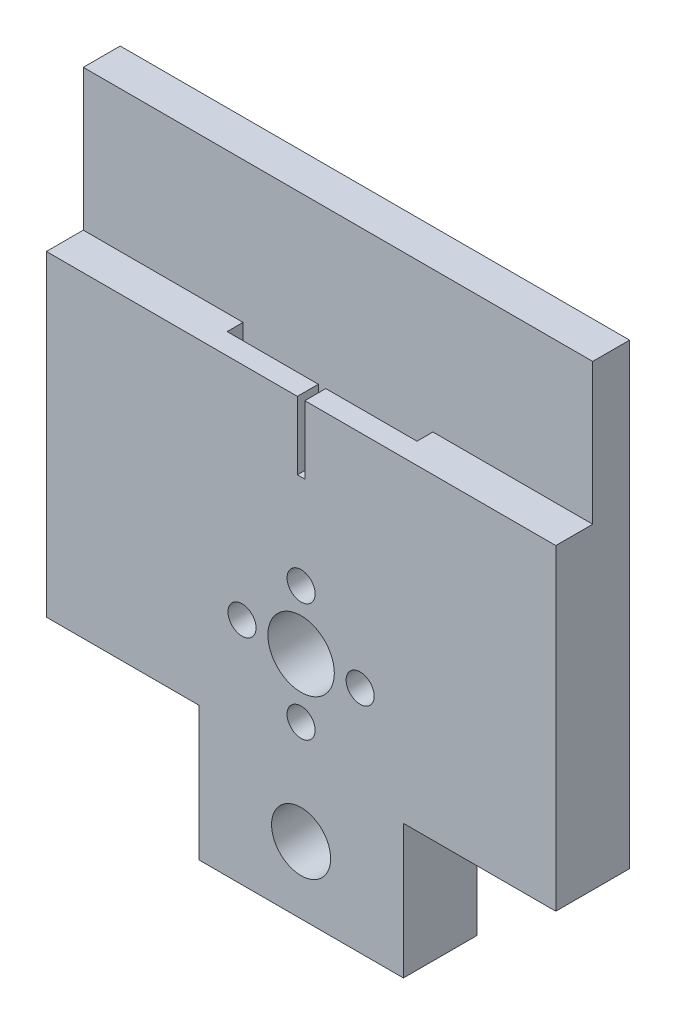
from build123d import *

# Parameters (mm, degrees)
BOSS_EXTRUDE1_DEPTH     = 10
SKETCH2_R               = 4
SKETCH2_R_2             = 4.5
SKETCH2_R_3             = 1.9
CUT_EXTRUDE1_DEPTH      = 11
CUT_EXTRUDE2_DEPTH      = 1
CUT_EXTRUDE2_DEPTH_BACK = 70
SKETCH5_W               = 1.016
SKETCH5_H               = 9.2075
CUT_EXTRUDE4_DEPTH      = 5
SKETCH6_W               = 12.35
SKETCH6_H               = 2.159
CUT_EXTRUDE5_DEPTH      = 9.954
SKETCH7_W               = 12.35
SKETCH7_H               = 2.159
CUT_EXTRUDE6_DEPTH      = 9.954


with BuildPart() as part:
    # Sketch1 → Boss-Extrude1 (new body)
    with BuildSketch(Plane.XY):
        Polygon((-34.5, 40.07390675), (34.5, 40.07390675), (34.5, -21.92609325), (13.861088822, -21.92609325), (13.861088822, -40.07390675), (-13.861088822, -40.07390675), (-13.861088822, -21.92609325), (-34.5, -21.92609325), align=None)
    extrude(amount=BOSS_EXTRUDE1_DEPTH)

    # Sketch2 → Cut-Extrude1 (cut, through all)
    with BuildSketch(Plane.XY.offset(10)):
        with Locations((0, -31)):
            Circle(SKETCH2_R)
        with Locations((0, -9)):
            Circle(SKETCH2_R_2)
        with Locations((0, -1)):
            Circle(SKETCH2_R_3)
        with Locations((8, -9)):
            Circle(SKETCH2_R_3)
        with Locations((0, -17)):
            Circle(SKETCH2_R_3)
        with Locations((-8, -9)):
            Circle(SKETCH2_R_3)
    extrude(amount=-CUT_EXTRUDE1_DEPTH, mode=Mode.SUBTRACT)

    # Sketch4 → Cut-Extrude2 (cut, two sides)
    with BuildSketch(Plane.ZY.offset(34.5)) as cut_extrude2_sk:
        Polygon((5, 210.681154515), (5, 40.07390675), (5, 20.97390675), (10, 20.97390675), (180.607247765, 20.97390675), (431.008352756, 252.763937984), (255.401104991, 442.471185749), align=None)
    extrude(amount=CUT_EXTRUDE2_DEPTH, mode=Mode.SUBTRACT)
    extrude(cut_extrude2_sk.sketch, amount=-CUT_EXTRUDE2_DEPTH_BACK, mode=Mode.SUBTRACT)

    # Sketch5 → Cut-Extrude4 (cut)
    with BuildSketch(Plane.XY.offset(10)):
        with Locations((0, 16.37015675)):
            Rectangle(SKETCH5_W, SKETCH5_H)
    extrude(amount=-CUT_EXTRUDE4_DEPTH, mode=Mode.SUBTRACT)

    # Sketch6 → Cut-Extrude5 (cut)
    with BuildSketch(Plane(origin=(0, 20.97390675, 0), x_dir=(1, 0, 0), z_dir=(0, 1, 0))):
        with Locations((-6.683, -6.0795)):
            Rectangle(SKETCH6_W, SKETCH6_H)
    extrude(amount=-CUT_EXTRUDE5_DEPTH, mode=Mode.SUBTRACT)

    # Sketch7 → Cut-Extrude6 (cut)
    with BuildSketch(Plane(origin=(0, 20.97390675, 0), x_dir=(1, 0, 0), z_dir=(0, 1, 0))):
        with Locations((6.683, -6.0795)):
            Rectangle(SKETCH7_W, SKETCH7_H)
    extrude(amount=-CUT_EXTRUDE6_DEPTH, mode=Mode.SUBTRACT)


solid = part.part
